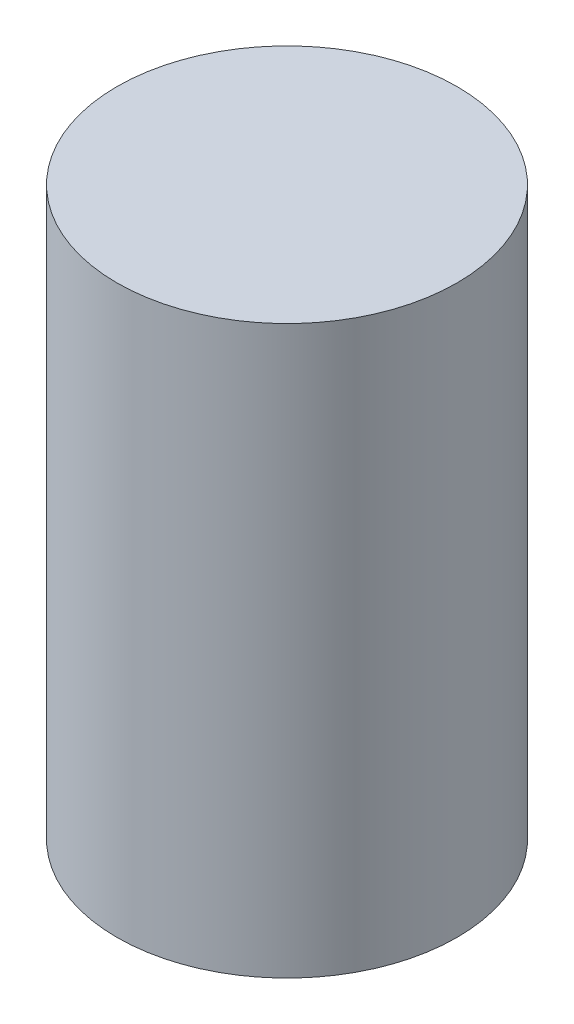
from build123d import *

# Parameters (mm, degrees)
SKETCH1_R           = 3.81
BOSS_EXTRUDE1_DEPTH = 12.7


with BuildPart() as part:
    # Sketch1 → Boss-Extrude1 (new body)
    with BuildSketch(Plane(origin=(0, 0, 0), x_dir=(1, 0, 0), z_dir=(0, 1, 0))):
        Circle(SKETCH1_R)
    extrude(amount=BOSS_EXTRUDE1_DEPTH)


solid = part.part
